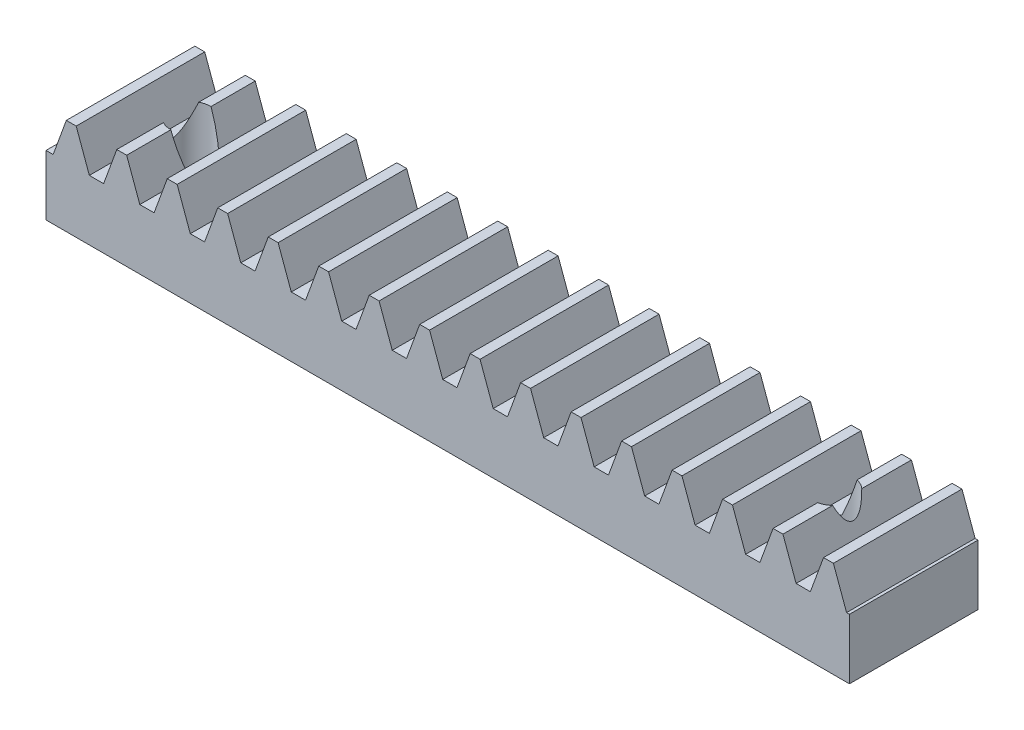
from build123d import *

# Parameters (mm, degrees)
BLANKSKE_W         = 50
BLANKSKE_H         = 6
BLANK_DEPTH        = 8
TOOTHCUTSIM_DEPTH  = 51.990195136
TEETHCUTS_COUNT    = 17
TEETHCUTS_PITCH    = 3.14159265
SKETCH1_R          = 1.25
CUT_EXTRUDE1_DEPTH = 10


with BuildPart() as part:
    # BlankSke → Blank (new body)
    with BuildSketch(Plane.XY):
        with Locations((25, 3)):
            Rectangle(BLANKSKE_W, BLANKSKE_H)
    extrude(amount=-BLANK_DEPTH)

    # TooCutSkeSim → ToothCutSim (cut, through all)
    with BuildSketch(Plane.XY):
        Polygon((0.44443537, 3.75), (-0.44443537, 3.75), (-1.272613241, 6.0254), (1.272613241, 6.0254), align=None)
    toothcutsim = extrude(amount=-TOOTHCUTSIM_DEPTH, mode=Mode.SUBTRACT)

    # TeethCuts: ToothCutSim ×17
    with Locations(*[(i * TEETHCUTS_PITCH, 0, 0) for i in range(1, TEETHCUTS_COUNT)]):
        add(toothcutsim, mode=Mode.SUBTRACT)

    # Sketch1 → Cut-Extrude1 (cut)
    with BuildSketch(Plane(origin=(0, 0, 0), x_dir=(-1, 0, 0), z_dir=(0, -1, 0))):
        with Locations(Location((-45, 4, 0), (0, 0, 90))):
            Circle(SKETCH1_R)
        with Locations(Location((-5, 4, 0), (0, 0, 90))):
            Circle(SKETCH1_R)
    extrude(amount=-CUT_EXTRUDE1_DEPTH, mode=Mode.SUBTRACT)


solid = part.part
